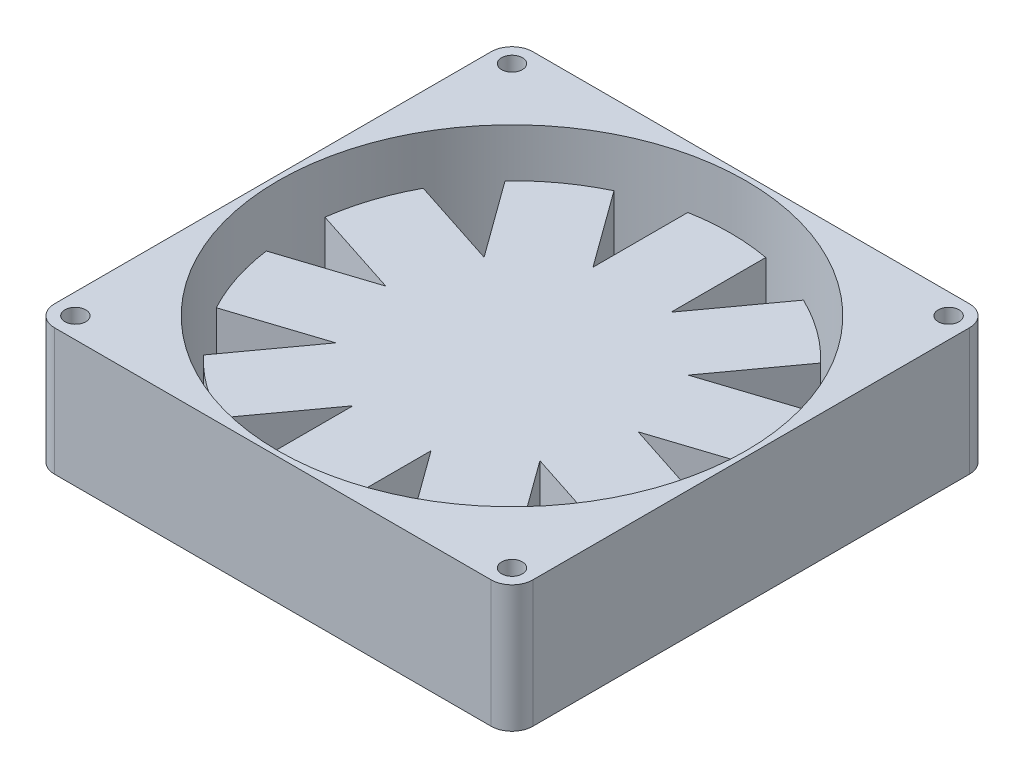
from build123d import *

# Parameters (mm, degrees)
ESBO_O1_W                = 92
ESBO_O1_H                = 92
RESSALTO_EXTRUS_O1_DEPTH = 24.4
ESBO_O2_R                = 2
CORTE_EXTRUS_O1_DEPTH    = 25.4
FILETE1_R                = 4
ESBO_O3_R                = 45
CORTE_EXTRUS_O3_DEPTH    = 25.4
RESSALTO_EXTRUS_O2_DEPTH = 15


with BuildPart() as part:
    # Esboço1 → Ressalto-extrusão1 (new body)
    with BuildSketch(Plane(origin=(0, 0, 0), x_dir=(1, 0, 0), z_dir=(0, 1, 0))):
        Rectangle(ESBO_O1_W, ESBO_O1_H)
    extrude(amount=RESSALTO_EXTRUS_O1_DEPTH)

    # Esboço2 → Corte-extrusão1 (cut, through all)
    with BuildSketch(Plane(origin=(0, 24.4, 0), x_dir=(1, 0, 0), z_dir=(0, 1, 0))):
        with Locations((42, 42)):
            Circle(ESBO_O2_R)
        with Locations((-42, 42)):
            Circle(ESBO_O2_R)
        with Locations((42, -42)):
            Circle(ESBO_O2_R)
        with Locations((-42, -42)):
            Circle(ESBO_O2_R)
    extrude(amount=-CORTE_EXTRUS_O1_DEPTH, mode=Mode.SUBTRACT)

    # Filete1
    filete1_edges = [part.edges().sort_by_distance(p)[0] for p in [
        (-46, 12.2, -46),
        (46, 12.2, -46),
        (46, 12.2, 46),
        (-46, 12.2, 46),
    ]]
    fillet(filete1_edges, radius=FILETE1_R)

    # Esboço3 → Corte-extrusão3 (cut, through all)
    with BuildSketch(Plane(origin=(0, 24.4, 0), x_dir=(1, 0, 0), z_dir=(0, 1, 0))):
        Circle(ESBO_O3_R)
    extrude(amount=-CORTE_EXTRUS_O3_DEPTH, mode=Mode.SUBTRACT)


with BuildPart() as body_2:
    # Esboço4 → Ressalto-extrusão2 (new body)
    with BuildSketch(Plane(origin=(0, 17.2, 0), x_dir=(1, 0, 0), z_dir=(0, 1, 0))):
        with BuildLine():
            Line((-7.5, 41.324931942), (-7.5, 23.082626529))
            Line((-7.5, 23.082626529), (-18.22255809, 37.840961625))
            ThreePointArc((-18.22255809, 37.840961625), (-24.686980596, 33.978713764), (-30.357813005, 29.02418284))
            Line((-30.357813005, 29.02418284), (-19.635254916, 14.265847744))
            Line((-19.635254916, 14.265847744), (-36.984718351, 19.903030134))
            ThreePointArc((-36.984718351, 19.903030134), (-39.944373684, 12.978713764), (-41.619973267, 5.637182389))
            Line((-41.619973267, 5.637182389), (-24.270509831, 0))
            Line((-24.270509831, 0), (-41.619973267, -5.637182389))
            ThreePointArc((-41.619973267, -5.637182389), (-39.944373684, -12.978713764), (-36.984718351, -19.903030134))
            Line((-36.984718351, -19.903030134), (-19.635254916, -14.265847744))
            Line((-19.635254916, -14.265847744), (-30.357813005, -29.02418284))
            ThreePointArc((-30.357813005, -29.02418284), (-24.686980596, -33.978713764), (-18.22255809, -37.840961625))
            Line((-18.22255809, -37.840961625), (-7.5, -23.082626529))
            Line((-7.5, -23.082626529), (-7.5, -41.324931942))
            ThreePointArc((-7.5, -41.324931942), (0, -42), (7.5, -41.324931942))
            Line((7.5, -41.324931942), (7.5, -23.082626529))
            Line((7.5, -23.082626529), (18.22255809, -37.840961625))
            ThreePointArc((18.22255809, -37.840961625), (24.686980596, -33.978713764), (30.357813005, -29.02418284))
            Line((30.357813005, -29.02418284), (19.635254916, -14.265847744))
            Line((19.635254916, -14.265847744), (36.984718351, -19.903030134))
            ThreePointArc((36.984718351, -19.903030134), (39.944373684, -12.978713764), (41.619973267, -5.637182389))
            Line((41.619973267, -5.637182389), (24.270509831, 0))
            Line((24.270509831, 0), (41.619973267, 5.637182389))
            ThreePointArc((41.619973267, 5.637182389), (39.944373684, 12.978713764), (36.984718351, 19.903030134))
            Line((36.984718351, 19.903030134), (19.635254916, 14.265847744))
            Line((19.635254916, 14.265847744), (30.357813005, 29.02418284))
            ThreePointArc((30.357813005, 29.02418284), (24.686980596, 33.978713764), (18.22255809, 37.840961625))
            Line((18.22255809, 37.840961625), (7.5, 23.082626529))
            Line((7.5, 23.082626529), (7.5, 41.324931942))
            ThreePointArc((7.5, 41.324931942), (0, 42), (-7.5, 41.324931942))
        make_face()
    extrude(amount=-RESSALTO_EXTRUS_O2_DEPTH)


solid = Compound([part.part, body_2.part])
